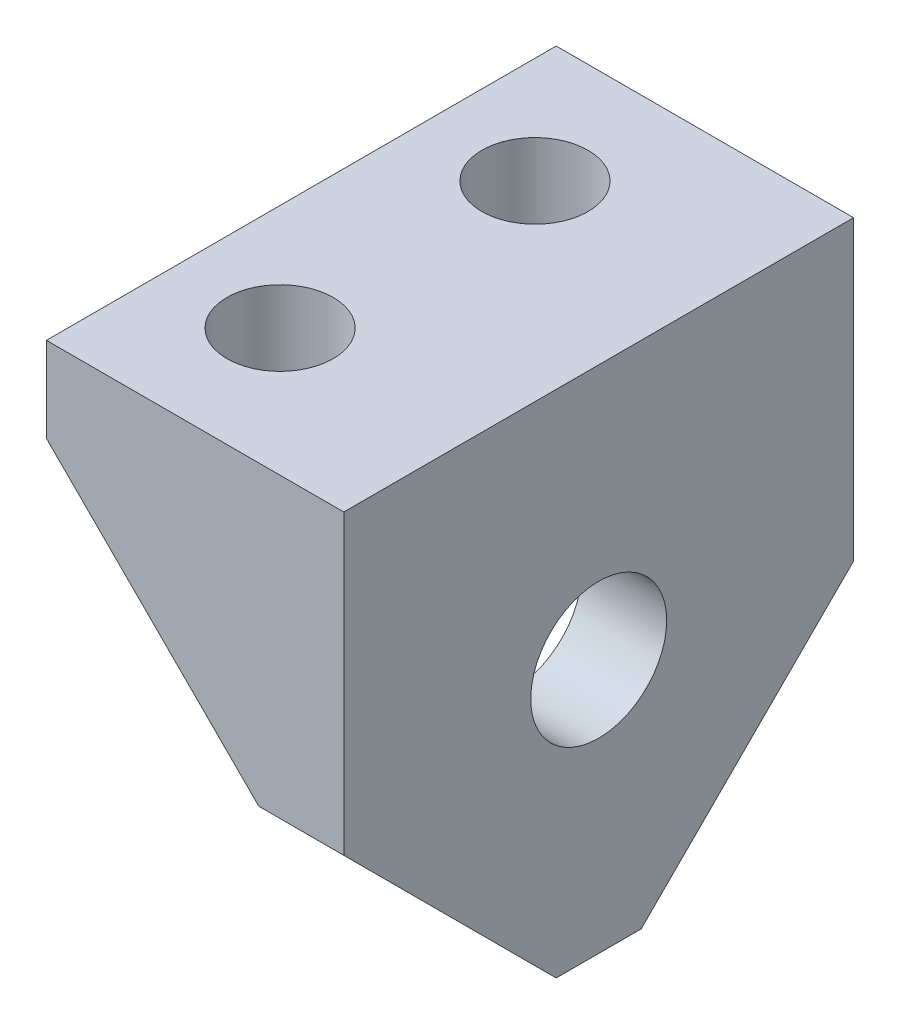
from build123d import *

# Parameters (mm, degrees)
SKETCH1_W           = 12
SKETCH1_H           = 12
BOSS_EXTRUDE1_DEPTH = 2
SKETCH3_W           = 12
SKETCH3_H           = 2
BOSS_EXTRUDE2_DEPTH = 5
CUT_EXTRUDE1_DEPTH  = 5
SKETCH5_R           = 1.6
CUT_EXTRUDE2_DEPTH  = 5
SKETCH7_R           = 1.25
CUT_EXTRUDE3_DEPTH  = 5
BOSS_EXTRUDE4_DEPTH = 1.5


with BuildPart() as part:
    # Sketch1 → Boss-Extrude1 (new body)
    with BuildSketch(Plane(origin=(0, 0, 0), x_dir=(0, 0, -1), z_dir=(1, 0, 0))):
        with Locations((0, -1.5)):
            Rectangle(SKETCH1_W, SKETCH1_H)
    extrude(amount=BOSS_EXTRUDE1_DEPTH)

    # Sketch3 → Boss-Extrude2 (add)
    with BuildSketch(Plane.ZY):
        with Locations((0, 3.5)):
            Rectangle(SKETCH3_W, SKETCH3_H)
    extrude(amount=BOSS_EXTRUDE2_DEPTH)

    # Sketch4 → Cut-Extrude1 (cut)
    with BuildSketch(Plane(origin=(2, 0, 0), x_dir=(0, 0, -1), z_dir=(1, 0, 0))):
        Polygon((-6, -2.5), (-1, -7.5), (-6, -7.5), align=None)
        Polygon((1, -7.5), (6, -7.5), (6, -2.5), align=None)
    extrude(amount=-CUT_EXTRUDE1_DEPTH, mode=Mode.SUBTRACT)

    # Sketch5 → Cut-Extrude2 (cut)
    with BuildSketch(Plane(origin=(2, 0, 0), x_dir=(0, 0, -1), z_dir=(1, 0, 0))):
        with Locations((0, -1.511770417)):
            Circle(SKETCH5_R)
    extrude(amount=-CUT_EXTRUDE2_DEPTH, mode=Mode.SUBTRACT)

    # Sketch7 → Cut-Extrude3 (cut)
    with BuildSketch(Plane.XZ.offset(-2.5)):
        with Locations((-2.5, 3)):
            Circle(SKETCH7_R)
        with Locations((-2.5, -3)):
            Circle(SKETCH7_R)
    extrude(amount=-CUT_EXTRUDE3_DEPTH, mode=Mode.SUBTRACT)

    # Sketch8 → Boss-Extrude4 (add)
    with BuildSketch(Plane.XY.offset(6)):
        Polygon((-5, 2.5), (0, 2.5), (0, -2.5), align=None)
    boss_extrude4 = extrude(amount=-BOSS_EXTRUDE4_DEPTH)

    # Mirror1: Boss-Extrude4 across plane
    add(boss_extrude4.mirror(Plane.XY))


solid = part.part
